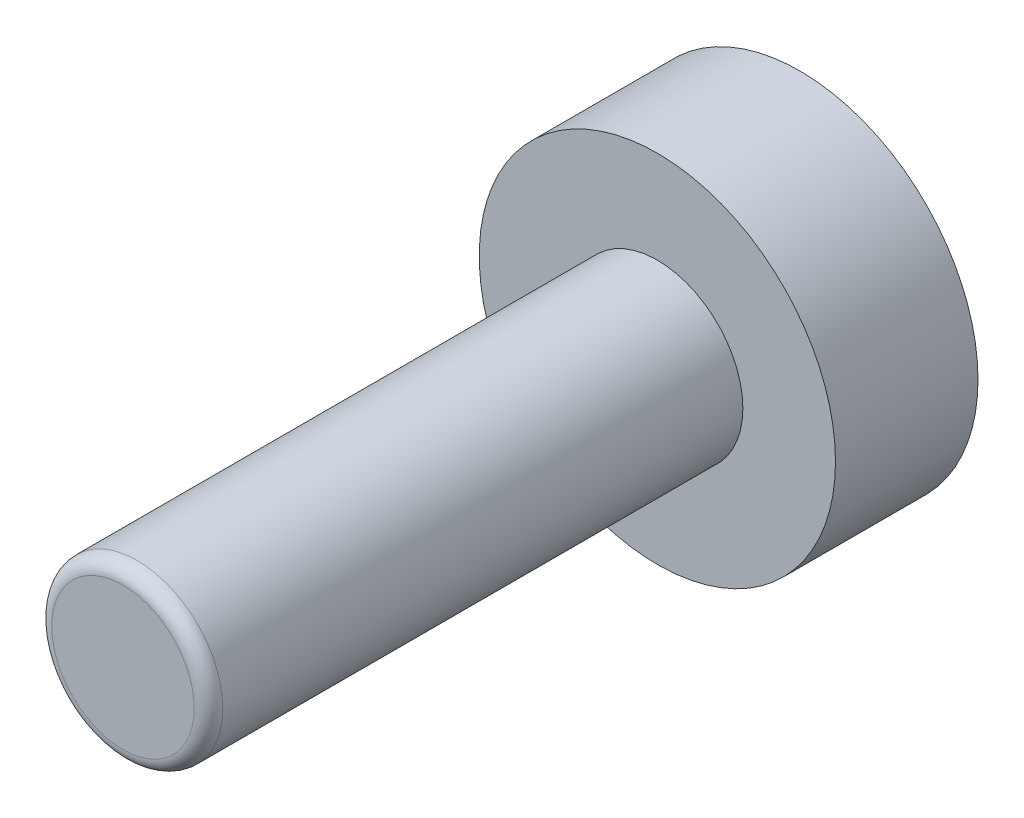
from build123d import *

# Parameters (mm, degrees)
ESQUISSE1_R        = 5
BOSS_EXTRU_1_DEPTH = 4
ESQUISSE2_R        = 2.4
BOSS_EXTRU_2_DEPTH = 15
CONG_1_R           = 0.4


with BuildPart() as part:
    # Esquisse1 → Boss.-Extru.1 (new body)
    with BuildSketch(Plane.XY):
        Circle(ESQUISSE1_R)
    extrude(amount=BOSS_EXTRU_1_DEPTH)

    # Esquisse2 → Boss.-Extru.2 (add)
    with BuildSketch(Plane.XY.offset(4)):
        Circle(ESQUISSE2_R)
    extrude(amount=BOSS_EXTRU_2_DEPTH)

    # Congé1
    cong_1_edges = [part.edges().sort_by_distance(p)[0] for p in [
        (-2.4, 0, 19),
    ]]
    fillet(cong_1_edges, radius=CONG_1_R)


solid = part.part
